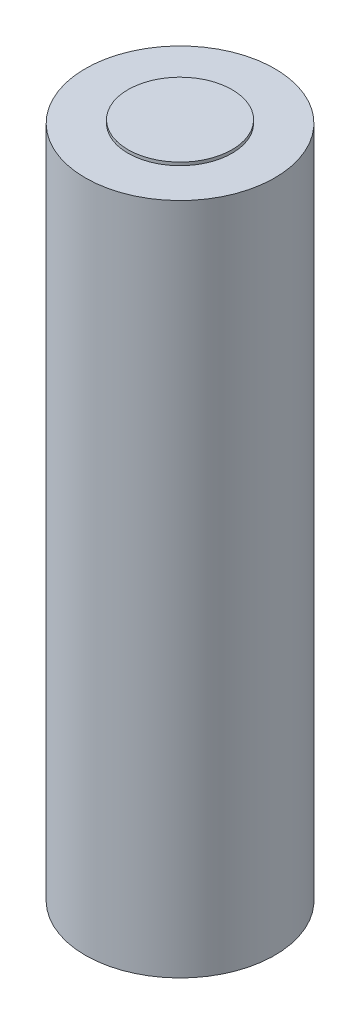
from build123d import *

# Parameters (mm, degrees)
SKETCH1_R           = 9.1
BOSS_EXTRUDE1_DEPTH = 64.7
SKETCH2_R           = 5
BOSS_EXTRUDE2_DEPTH = 0.3


with BuildPart() as part:
    # Sketch1 → Boss-Extrude1 (new body)
    with BuildSketch(Plane(origin=(0, 0, 0), x_dir=(1, 0, 0), z_dir=(0, 1, 0))):
        Circle(SKETCH1_R)
    extrude(amount=BOSS_EXTRUDE1_DEPTH)

    # Sketch2 → Boss-Extrude2 (add)
    with BuildSketch(Plane(origin=(0, 64.7, 0), x_dir=(1, 0, 0), z_dir=(0, 1, 0))):
        Circle(SKETCH2_R)
    extrude(amount=BOSS_EXTRUDE2_DEPTH)


solid = part.part
